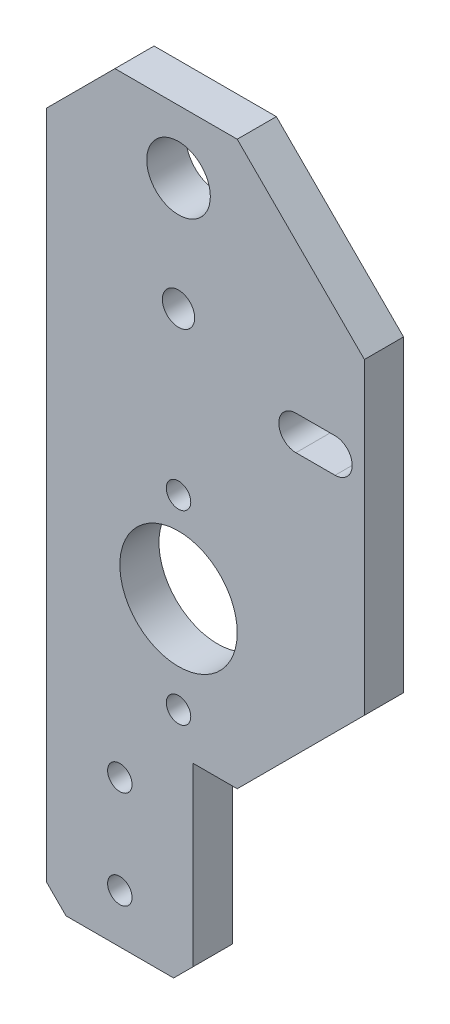
from build123d import *

# Parameters (mm, degrees)
SKETCH1_R             = 6
SKETCH1_R_2           = 3.25
BOSS_EXTRUDE1_DEPTH   = 4
CHAMFER1_SIZE         = 7
CHAMFER2_SIZE         = 13
CHAMFER3_SIZE         = 2
M4_TAPPED_HOLE1_D     = 3.3
M4_TAPPED_HOLE1_DEPTH = 10.1
M4_TAPPED_HOLE1_TIP   = 0.991420021
M3_TAPPED_HOLE1_D     = 2.5
M3_TAPPED_HOLE1_DEPTH = 7.5
M3_TAPPED_HOLE1_TIP   = 0.751075774


with BuildPart() as part:
    # Sketch1 → Boss-Extrude1 (new body)
    with BuildSketch(Plane.XY):
        Polygon((-22.131578947, 33.105263158), (10.368421053, 33.105263158), (10.368421053, -24.394736842), (-7.131578947, -24.394736842), (-7.131578947, -44.394736842), (-22.131578947, -44.394736842), align=None)
        with Locations((-8.631578947, -10.578947368)):
            Circle(SKETCH1_R, mode=Mode.SUBTRACT)
        with Locations((-8.631578947, 26.657894737)):
            Circle(SKETCH1_R_2, mode=Mode.SUBTRACT)
        with BuildLine():
            Line((3.368421053, 11.855263158), (7.368421053, 11.855263158))
            ThreePointArc((7.368421053, 11.855263158), (9.118421053, 10.105263158), (7.368421053, 8.355263158))
            Line((7.368421053, 8.355263158), (3.368421053, 8.355263158))
            ThreePointArc((3.368421053, 8.355263158), (1.618421053, 10.105263158), (3.368421053, 11.855263158))
        make_face(mode=Mode.SUBTRACT)
    extrude(amount=BOSS_EXTRUDE1_DEPTH)

    # Chamfer1
    chamfer1_edges = [part.edges().sort_by_distance(p)[0] for p in [
        (-22.131578947, 33.105263158, 2),
    ]]
    chamfer(chamfer1_edges, length=CHAMFER1_SIZE)

    # Chamfer2
    chamfer2_edges = [part.edges().sort_by_distance(p)[0] for p in [
        (10.368421053, 33.105263158, 2),
        (10.368421053, -24.394736842, 2),
    ]]
    chamfer(chamfer2_edges, length=CHAMFER2_SIZE)

    # Chamfer3
    chamfer3_edges = [part.edges().sort_by_distance(p)[0] for p in [
        (-7.131578947, -44.394736842, 2),
        (-22.131578947, -44.394736842, 2),
    ]]
    chamfer(chamfer3_edges, length=CHAMFER3_SIZE)

    # M4 Tapped Hole1
    with Locations(Plane.XY.offset(4)):
        with Locations((-8.631578947, 15.105263158)):
            Hole(M4_TAPPED_HOLE1_D / 2, depth=M4_TAPPED_HOLE1_DEPTH)
            with Locations((0, 0, -(M4_TAPPED_HOLE1_DEPTH + M4_TAPPED_HOLE1_TIP / 2))):  # 118° drill point
                Cone(0, M4_TAPPED_HOLE1_D / 2, M4_TAPPED_HOLE1_TIP, mode=Mode.SUBTRACT)

    # M3 Tapped Hole1
    with Locations(Plane.XY.offset(4)):
        with Locations((-8.631578947, -1.394736842), (-8.631578947, -20.394736842), (-14.631578947, -29.394736842), (-14.631578947, -39.394736842)):
            Hole(M3_TAPPED_HOLE1_D / 2, depth=M3_TAPPED_HOLE1_DEPTH)
            with Locations((0, 0, -(M3_TAPPED_HOLE1_DEPTH + M3_TAPPED_HOLE1_TIP / 2))):  # 118° drill point
                Cone(0, M3_TAPPED_HOLE1_D / 2, M3_TAPPED_HOLE1_TIP, mode=Mode.SUBTRACT)


solid = part.part
